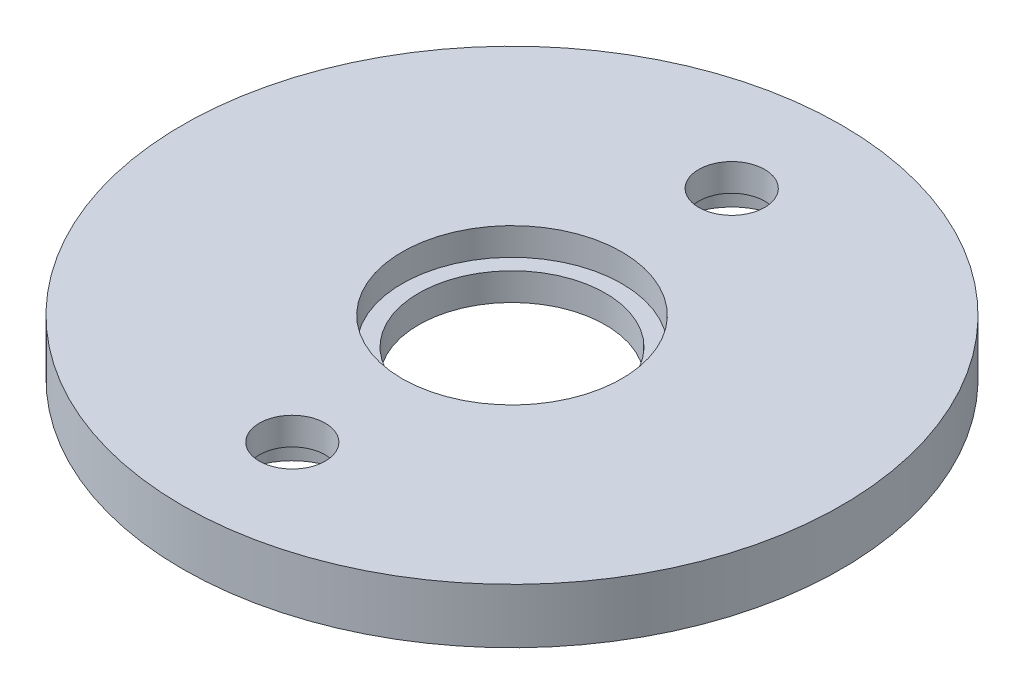
from build123d import *

# Parameters (mm, degrees)
SKETCH1_R           = 6
SKETCH1_R_2         = 1.7
SKETCH1_R_3         = 1
SKETCH1_R_4         = 0.6
BASEPLATE_DEPTH     = 1
SKETCH1_3_R         = 0.6
SCREWHOLES_DEPTH    = 2
SKETCH1_4_R         = 1
SKETCH1_4_R_2       = 0.6
SCREWHATSLOTS_DEPTH = 0.5
SKETCH2_R           = 2
BEARINGSLOT_DEPTH   = 0.5


with BuildPart() as part:
    # Sketch1 → BasePlate (new body)
    with BuildSketch(Plane(origin=(0, 0, 0), x_dir=(1, 0, 0), z_dir=(0, 1, 0))):
        Circle(SKETCH1_R)
        Circle(SKETCH1_R_2, mode=Mode.SUBTRACT)
        with Locations((0, 4)):
            Circle(SKETCH1_R_3, mode=Mode.SUBTRACT)
        with Locations((0, -4)):
            Circle(SKETCH1_R_3, mode=Mode.SUBTRACT)
        with Locations((0, -4)):
            Circle(SKETCH1_R_4)
        with Locations((0, 4)):
            Circle(SKETCH1_R_4)
        with Locations((0, 4)):
            Circle(SKETCH1_R_3)
        with Locations((0, 4)):
            Circle(SKETCH1_R_4, mode=Mode.SUBTRACT)
        with Locations((0, -4)):
            Circle(SKETCH1_R_3)
        with Locations((0, -4)):
            Circle(SKETCH1_R_4, mode=Mode.SUBTRACT)
    extrude(amount=BASEPLATE_DEPTH)

    # Sketch1_3 → ScrewHoles (cut, through all)
    with BuildSketch(Plane(origin=(0, 0, 0), x_dir=(1, 0, 0), z_dir=(0, 1, 0))):
        with Locations((0, -4)):
            Circle(SKETCH1_3_R)
        with Locations((0, 4)):
            Circle(SKETCH1_3_R)
    extrude(amount=SCREWHOLES_DEPTH, mode=Mode.SUBTRACT)

    # Sketch1_4 → ScrewHatSlots (cut)
    with BuildSketch(Plane(origin=(0, 0, 0), x_dir=(1, 0, 0), z_dir=(0, 1, 0))):
        with Locations((0, -4)):
            Circle(SKETCH1_4_R)
        with Locations((0, -4)):
            Circle(SKETCH1_4_R_2, mode=Mode.SUBTRACT)
        with Locations((0, 4)):
            Circle(SKETCH1_4_R)
        with Locations((0, 4)):
            Circle(SKETCH1_4_R_2, mode=Mode.SUBTRACT)
    extrude(amount=SCREWHATSLOTS_DEPTH, mode=Mode.SUBTRACT)

    # Sketch2 → BearingSlot (cut)
    with BuildSketch(Plane(origin=(0, 1, 0), x_dir=(1, 0, 0), z_dir=(0, 1, 0))):
        Circle(SKETCH2_R)
    extrude(amount=-BEARINGSLOT_DEPTH, mode=Mode.SUBTRACT)


solid = part.part
